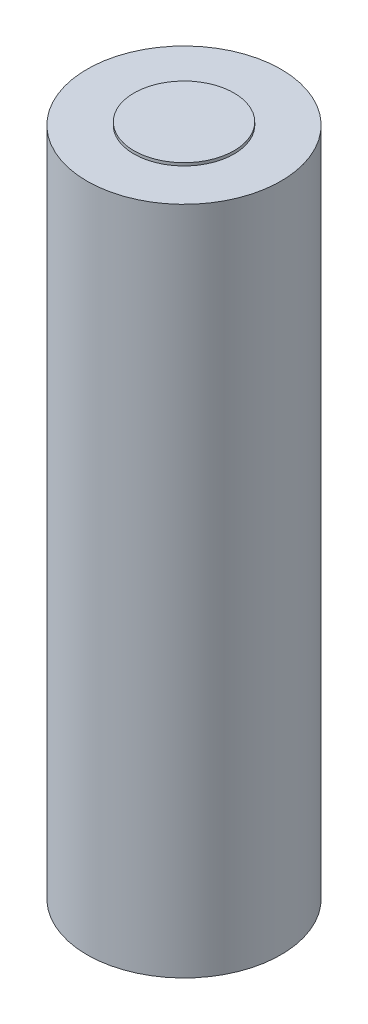
from build123d import *

# Parameters (mm, degrees)
SKETCH1_R           = 10.175
BOSS_EXTRUDE1_DEPTH = 70.3
SKETCH2_R           = 5.25
BOSS_EXTRUDE2_DEPTH = 0.3


with BuildPart() as part:
    # Sketch1 → Boss-Extrude1 (new body)
    with BuildSketch(Plane(origin=(0, 0, 0), x_dir=(1, 0, 0), z_dir=(0, 1, 0))):
        Circle(SKETCH1_R)
    extrude(amount=BOSS_EXTRUDE1_DEPTH)

    # Sketch2 → Boss-Extrude2 (add)
    with BuildSketch(Plane(origin=(0, 70.3, 0), x_dir=(1, 0, 0), z_dir=(0, 1, 0))):
        Circle(SKETCH2_R)
    extrude(amount=BOSS_EXTRUDE2_DEPTH)


solid = part.part
